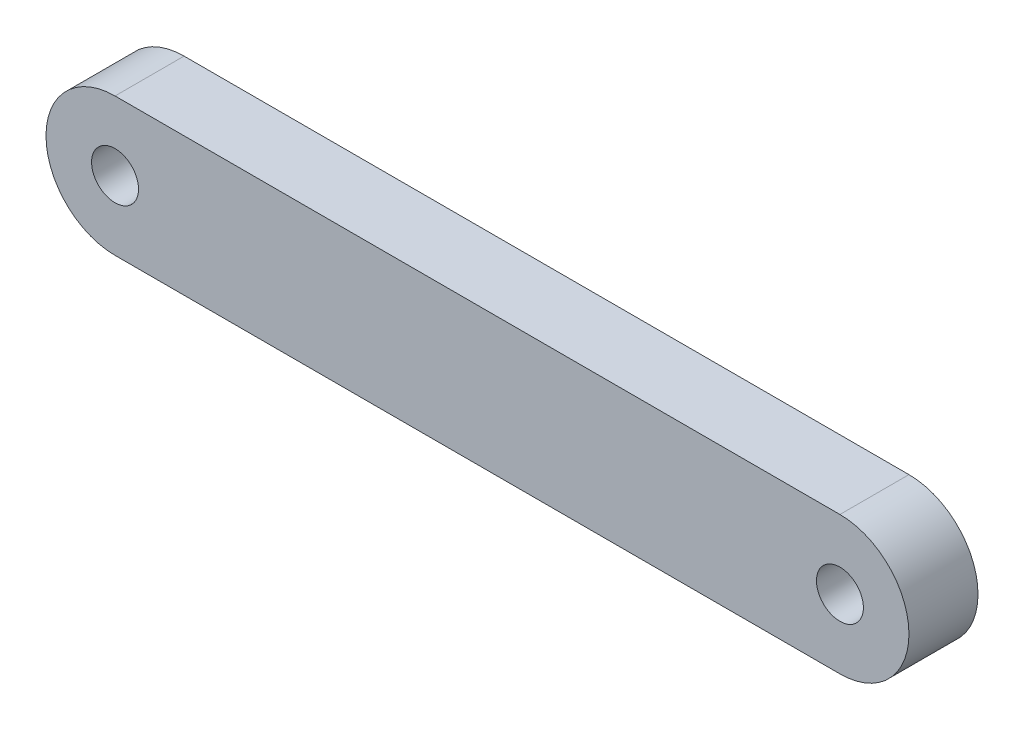
from build123d import *

# Parameters (mm, degrees)
SKETCH1_R           = 2.159
BOSS_EXTRUDE1_DEPTH = 6.35


with BuildPart() as part:
    # Sketch1 → Boss-Extrude1 (new body)
    with BuildSketch(Plane.XY):
        with BuildLine():
            Line((0, 6.35), (66.675, 6.35))
            ThreePointArc((66.675, 6.35), (73.025, 0), (66.675, -6.35))
            Line((66.675, -6.35), (0, -6.35))
            ThreePointArc((0, -6.35), (-6.35, 0), (0, 6.35))
        make_face()
        Circle(SKETCH1_R, mode=Mode.SUBTRACT)
        with Locations((66.675, 0)):
            Circle(SKETCH1_R, mode=Mode.SUBTRACT)
    extrude(amount=BOSS_EXTRUDE1_DEPTH)


solid = part.part
